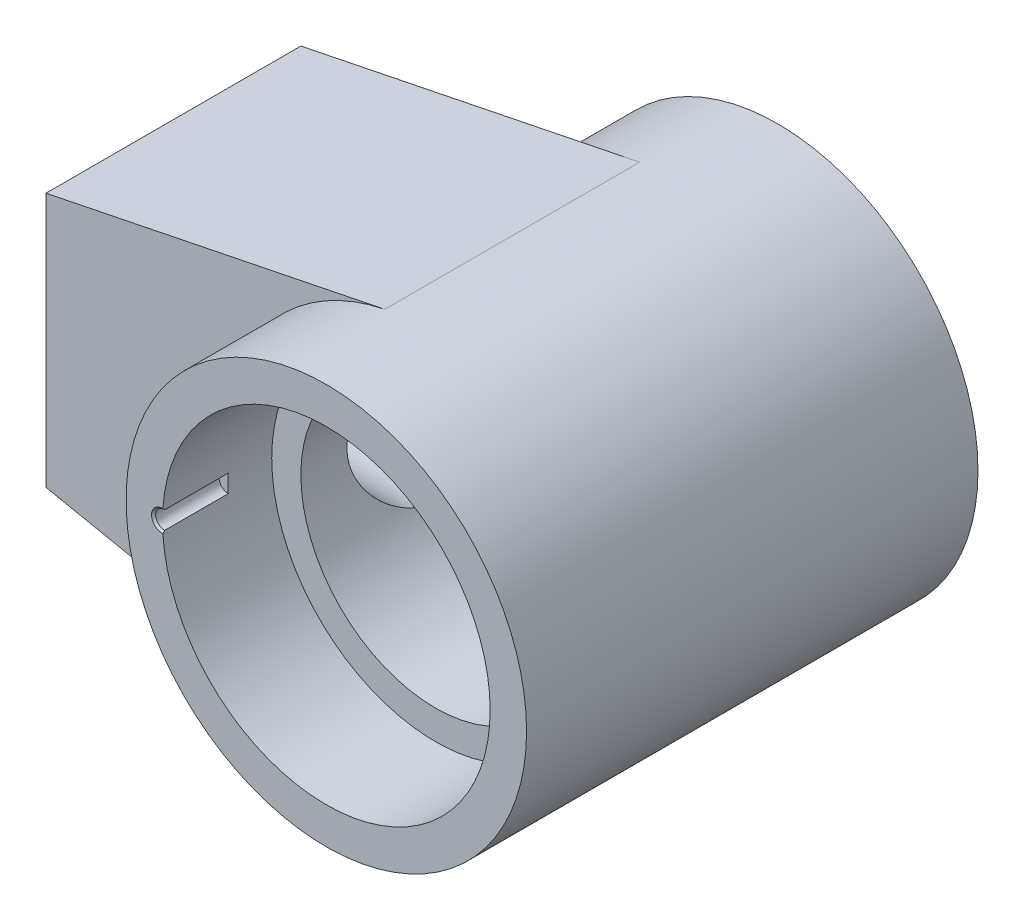
from build123d import *

# Parameters (mm, degrees)
SKETCH_1_R               = 55
EXTRUDE_1_DEPTH          = 62
EXTRUDE_2_DEPTH          = 35
SKETCH_3_R               = 37
CUT_EXTRUDE_1_DEPTH      = 63
CUT_EXTRUDE_1_DEPTH_BACK = 63
SKETCH_4_R               = 45
CUT_EXTRUDE_2_DEPTH      = 30
CUT_EXTRUDE_3_REACH      = 161
SKETCH_6_R               = 19.352
CHAMFER_2_SIZE           = 1.648
SKETCH_9_R               = 2.4455
CUT_EXTRUDE_5_DEPTH      = 18
CHAMFER_3_SIZE           = 0.5545


with BuildPart() as part:
    # Эскиз1 → Бобышка-Вытянуть1 (new body, symmetric)
    with BuildSketch(Plane.XY):
        Circle(SKETCH_1_R)
    extrude(amount=EXTRUDE_1_DEPTH, both=True)

    # Эскиз2 → Бобышка-Вытянуть2 (add, symmetric)
    with BuildSketch(Plane.XY):
        Polygon((-104, 0), (-104, 35), (-10.947280704, 53.899508766), (-10.947280704, 0), align=None)
    extrude_2 = extrude(amount=EXTRUDE_2_DEPTH, both=True)

    # Зеркальное отражение1: Бобышка-Вытянуть2 across plane
    add(extrude_2.mirror(Plane(origin=(-104, 0, 35), x_dir=(0, 0, 1), z_dir=(0, 1, 0))))

    # Эскиз3 → Вырез-Вытянуть1 (cut, two sides)
    with BuildSketch(Plane.XY) as cut_extrude_1_sk:
        Circle(SKETCH_3_R)
    extrude(amount=CUT_EXTRUDE_1_DEPTH, mode=Mode.SUBTRACT)
    extrude(cut_extrude_1_sk.sketch, amount=-CUT_EXTRUDE_1_DEPTH_BACK, mode=Mode.SUBTRACT)

    # Эскиз4 → Вырез-Вытянуть2 (cut)
    with BuildSketch(Plane.XY.offset(62)):
        Circle(SKETCH_4_R)
    cut_extrude_2 = extrude(amount=-CUT_EXTRUDE_2_DEPTH, mode=Mode.SUBTRACT)

    # Зеркальное отражение2: Вырез-Вытянуть2 across plane
    add(cut_extrude_2.mirror(Plane.XY), mode=Mode.SUBTRACT)

    # Эскиз6 → Вырез-Вытянуть3 (cut, up to next)
    with BuildSketch(Plane.ZY.offset(104), mode=Mode.PRIVATE) as cut_extrude_3_sk1:
        Circle(SKETCH_6_R)
    cut_extrude_3_tool1 = extrude(cut_extrude_3_sk1.sketch, amount=-CUT_EXTRUDE_3_REACH, mode=Mode.PRIVATE) & part.part
    add(cut_extrude_3_tool1.solids().sort_by_distance((-104, 0, 0))[0], mode=Mode.SUBTRACT)

    # Фаска2
    chamfer_2_edges = [part.edges().sort_by_distance(p)[0] for p in [
        (-104, 0, -19.352),
    ]]
    chamfer(chamfer_2_edges, length=CHAMFER_2_SIZE)

    # Эскиз9 → Вырез-Вытянуть5 (cut)
    with BuildSketch(Plane(origin=(0, 0, -62), x_dir=(-1, 0, 0), z_dir=(0, 0, -1))):
        with Locations((45, 0)):
            Circle(SKETCH_9_R)
    cut_extrude_5 = extrude(amount=-CUT_EXTRUDE_5_DEPTH, mode=Mode.SUBTRACT)

    # Зеркальное отражение3: Вырез-Вытянуть5 across plane
    add(cut_extrude_5.mirror(Plane.XY), mode=Mode.SUBTRACT)

    # Фаска3
    chamfer_3_edges = [part.edges().sort_by_distance(p)[0] for p in [
        (-47.4455, 0, -62),
        (-47.4455, 0, 62),
    ]]
    chamfer(chamfer_3_edges, length=CHAMFER_3_SIZE)


solid = part.part
